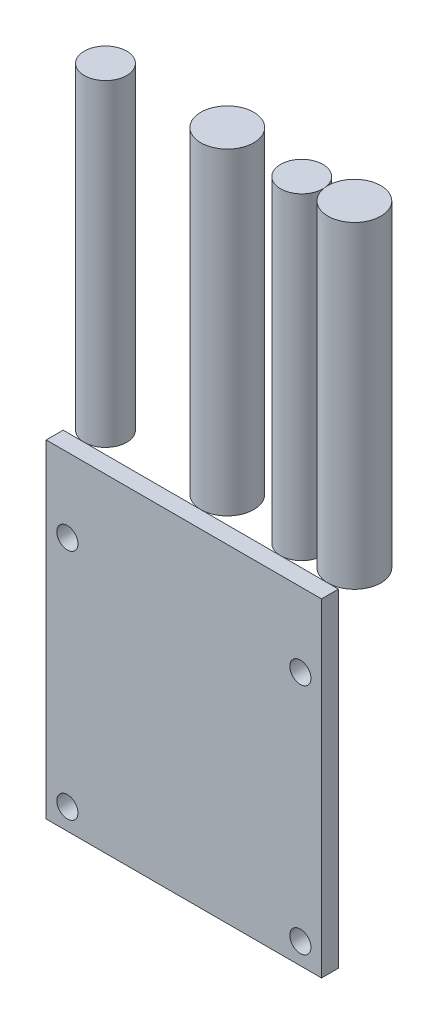
from build123d import *

# Parameters (mm, degrees)
SKETCH_1_W        = 26
SKETCH_1_H        = 31
SKETCH_1_R        = 1
EXTRUDE_1_DEPTH   = 0.8
SKETCH_3_R        = 2
EXTRUDE_2_DEPTH   = 30
SKETCH_3_R_2      = 2.5
EXTRUDE_2_2_DEPTH = 30
EXTRUDE_2_3_DEPTH = 30
EXTRUDE_2_4_DEPTH = 30


with BuildPart() as part:
    # Эскиз1 → Бобышка-Вытянуть1 (new body, symmetric)
    with BuildSketch(Plane.XY):
        Rectangle(SKETCH_1_W, SKETCH_1_H)
        with Locations((-11, -13.5)):
            Circle(SKETCH_1_R, mode=Mode.SUBTRACT)
        with Locations((11, -13.5)):
            Circle(SKETCH_1_R, mode=Mode.SUBTRACT)
        with Locations((11, 8.5)):
            Circle(SKETCH_1_R, mode=Mode.SUBTRACT)
        with Locations((-11, 8.5)):
            Circle(SKETCH_1_R, mode=Mode.SUBTRACT)
    extrude(amount=EXTRUDE_1_DEPTH, both=True)


with BuildPart() as body_2:
    # Эскиз3 → Бобышка-Вытянуть2 (new body)
    with BuildSketch(Plane(origin=(0, 15.5, 0), x_dir=(1, 0, 0), z_dir=(0, 1, 0))):
        with Locations((-11, 2.8)):
            Circle(SKETCH_3_R)
    extrude(amount=EXTRUDE_2_DEPTH)


with BuildPart() as body_3:
    # Эскиз3 → Extrude 2 2 (new body)
    with BuildSketch(Plane(origin=(0, 15.5, 0), x_dir=(1, 0, 0), z_dir=(0, 1, 0))):
        with Locations((0, 3.3)):
            Circle(SKETCH_3_R_2)
    extrude(amount=EXTRUDE_2_2_DEPTH)


with BuildPart() as body_4:
    # Эскиз3 → Extrude 2 3 (new body)
    with BuildSketch(Plane(origin=(0, 15.5, 0), x_dir=(1, 0, 0), z_dir=(0, 1, 0))):
        with Locations((7.527864045, 2.8)):
            Circle(SKETCH_3_R)
    extrude(amount=EXTRUDE_2_3_DEPTH)


with BuildPart() as body_5:
    # Эскиз3 → Extrude 2 4 (new body)
    with BuildSketch(Plane(origin=(0, 15.5, 0), x_dir=(1, 0, 0), z_dir=(0, 1, 0))):
        with Locations((12, 3.3)):
            Circle(SKETCH_3_R_2)
    extrude(amount=EXTRUDE_2_4_DEPTH)


solid = Compound([part.part, body_2.part, body_3.part, body_4.part, body_5.part])
